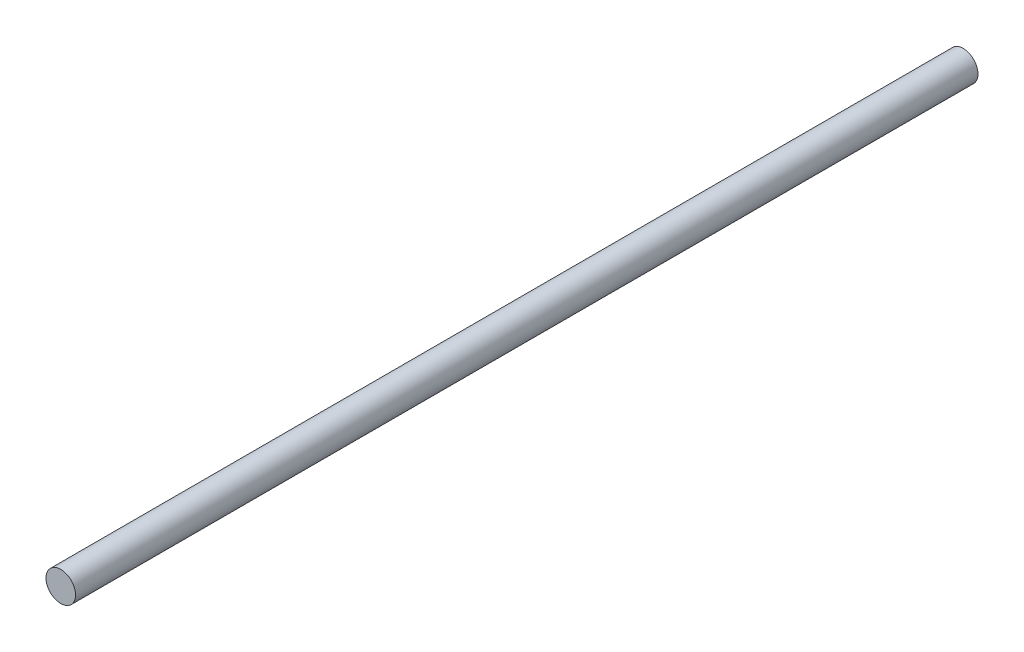
from build123d import *

# Parameters (mm, degrees)
SKETCH1_R           = 5
BOSS_EXTRUDE1_DEPTH = 305


with BuildPart() as part:
    # Sketch1 → Boss-Extrude1 (new body)
    with BuildSketch(Plane.XY):
        Circle(SKETCH1_R)
    extrude(amount=BOSS_EXTRUDE1_DEPTH)


solid = part.part
